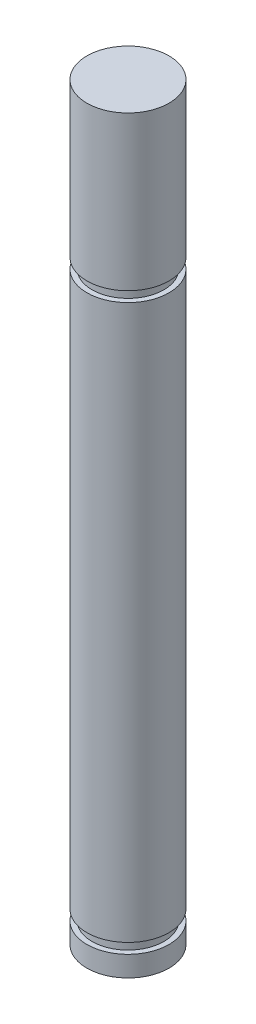
from build123d import *

# Parameters (mm, degrees)
SKETCH1_R           = 4
BOSS_EXTRUDE1_DEPTH = 73
SKETCH2_W           = 0.5
SKETCH2_H           = 1


with BuildPart() as part:
    # Sketch1 → Boss-Extrude1 (new body)
    with BuildSketch(Plane(origin=(0, 0, 0), x_dir=(1, 0, 0), z_dir=(0, 1, 0))):
        Circle(SKETCH1_R)
    extrude(amount=BOSS_EXTRUDE1_DEPTH)

    # Sketch2 → Cut-Revolve1 (revolve, cut)
    with BuildSketch(Plane.XY):
        with Locations((-3.75, 57.5)):
            Rectangle(SKETCH2_W, SKETCH2_H)
        with Locations((-3.75, 2.5)):
            Rectangle(SKETCH2_W, SKETCH2_H)
    revolve(axis=Axis((0, 73, 0), (0, -1, 0)), mode=Mode.SUBTRACT)


solid = part.part
